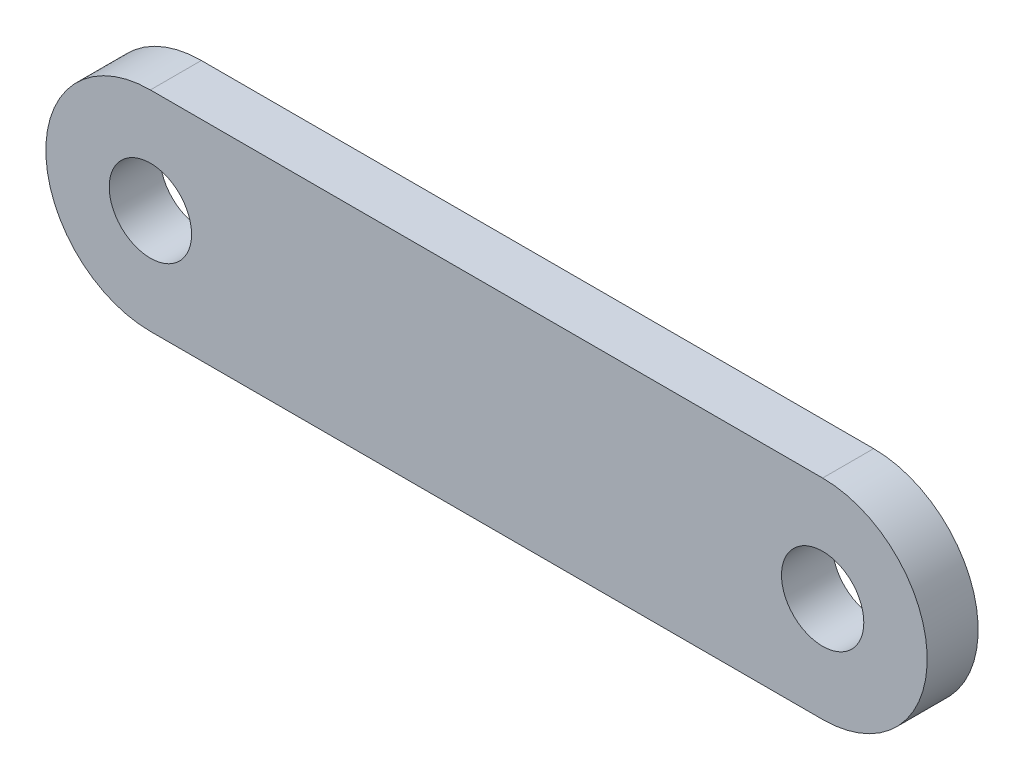
from build123d import *

# Parameters (mm, degrees)
SKETCH1_R           = 3.15
BOSS_EXTRUDE1_DEPTH = 3.9


with BuildPart() as part:
    # Sketch1 → Boss-Extrude1 (new body)
    with BuildSketch(Plane.XY):
        with BuildLine():
            Line((25.7175, -8), (-25.7175, -8))
            ThreePointArc((-25.7175, -8), (-33.7175, 0), (-25.7175, 8))
            Line((-25.7175, 8), (25.7175, 8))
            ThreePointArc((25.7175, 8), (33.7175, 0), (25.7175, -8))
        make_face()
        with Locations((25.7175, 0)):
            Circle(SKETCH1_R, mode=Mode.SUBTRACT)
        with Locations((-25.7175, 0)):
            Circle(SKETCH1_R, mode=Mode.SUBTRACT)
    extrude(amount=BOSS_EXTRUDE1_DEPTH)


solid = part.part
